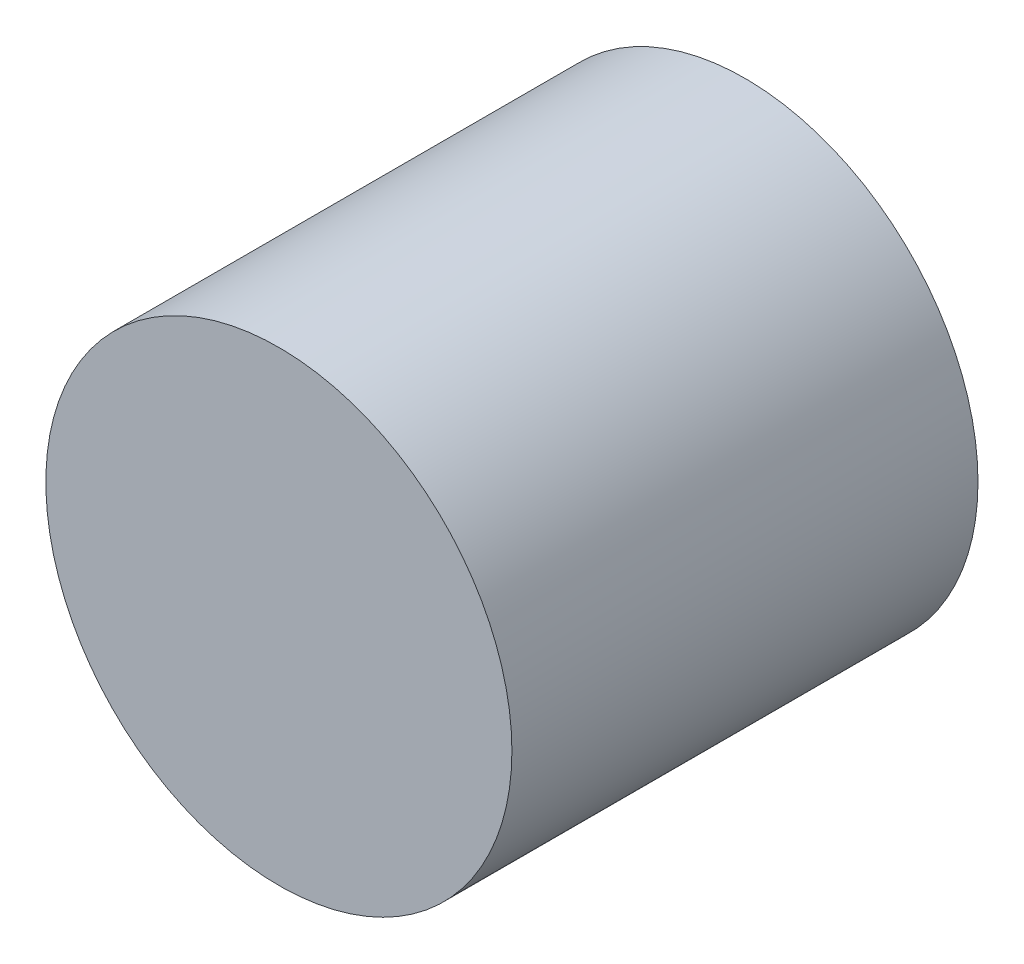
from build123d import *

# Parameters (mm, degrees)
SKETCH1_R           = 20.32
BOSS_EXTRUDE2_DEPTH = 40.64


with BuildPart() as part:
    # Sketch1 → Boss-Extrude2 (new body)
    with BuildSketch(Plane.XY):
        with Locations((2.638676679, 20.845545765)):
            Circle(SKETCH1_R)
    extrude(amount=BOSS_EXTRUDE2_DEPTH)


solid = part.part
